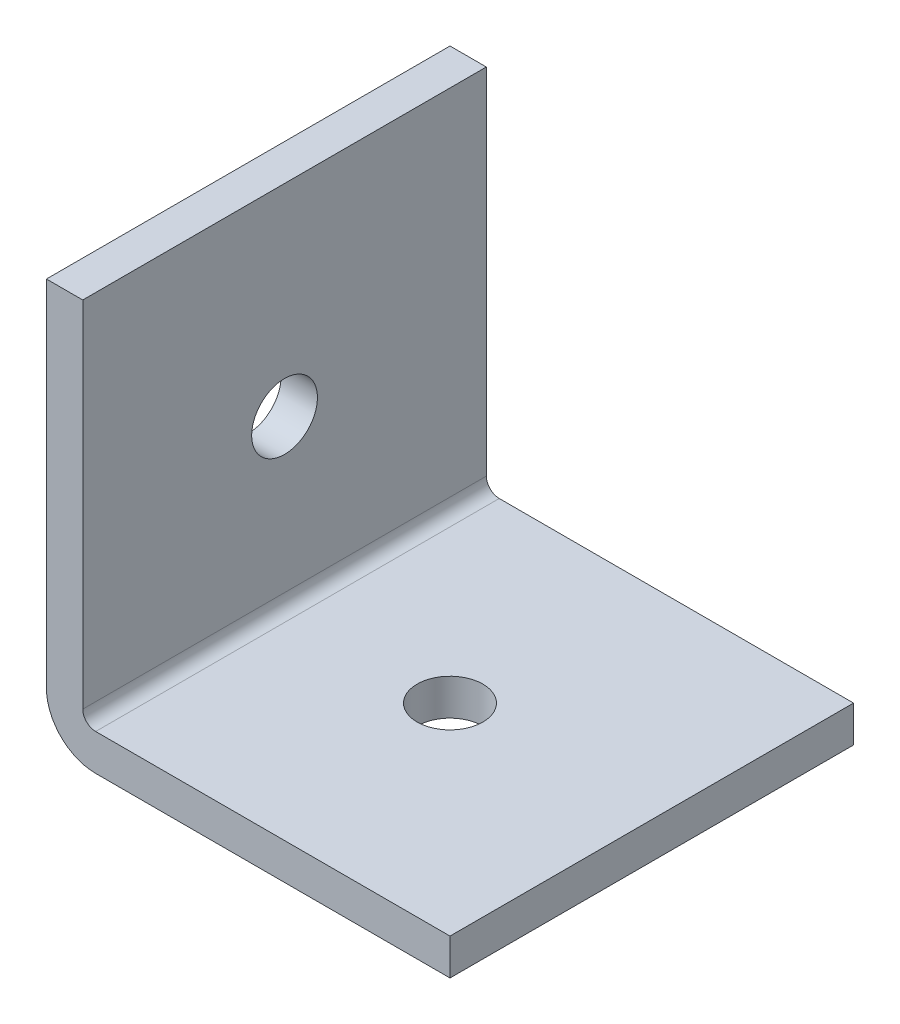
from build123d import *

# Parameters (mm, degrees)
SKETCH1_W                  = 25.4
SKETCH1_H                  = 1498.6
BOSS_EXTRUDE1_DEPTH        = 25.4
SKETCH2_W                  = 23.114
SKETCH2_H                  = 23.114
CUT_EXTRUDE1_DEPTH         = 1499.6
M3_5_CLEARANCE_HOLE1_D     = 4.1402
M3_5_CLEARANCE_HOLE1_DEPTH = 25.4
M3_5_CLEARANCE_HOLE2_D     = 4.1402
M3_5_CLEARANCE_HOLE2_DEPTH = 25.4
CHAMFER1_SIZE              = 2.159
FILLET1_R                  = 0.8128
FILLET2_R                  = 3.0988
SKETCH8_W                  = 95.882963774
SKETCH8_H                  = 79.338329604
CUT_EXTRUDE3_DEPTH         = 1371.6
SKETCH9_W                  = 56.924523055
SKETCH9_H                  = 51.282783217
CUT_EXTRUDE4_DEPTH         = 76.2
SKETCH10_W                 = 57.247248429
SKETCH10_H                 = 53.712272172
CUT_EXTRUDE5_DEPTH         = 25.4


with BuildPart() as part:
    # Sketch1 → Boss-Extrude1 (new body)
    with BuildSketch(Plane(origin=(0, 0, 0), x_dir=(0, -1, 0), z_dir=(-1, 0, 0))):
        with Locations((-12.7, 0)):
            Rectangle(SKETCH1_W, SKETCH1_H)
    extrude(amount=-BOSS_EXTRUDE1_DEPTH)

    # Sketch2 → Cut-Extrude1 (cut, through all)
    with BuildSketch(Plane(origin=(0, 0, -749.3), x_dir=(-1, 0, 0), z_dir=(0, 0, -1))):
        with Locations((-13.843, 13.843)):
            Rectangle(SKETCH2_W, SKETCH2_H)
    extrude(amount=-CUT_EXTRUDE1_DEPTH, mode=Mode.SUBTRACT)

    # M3.5 Clearance Hole1
    with Locations(Plane(origin=(0, 0, 0), x_dir=(-1, 0, 0), z_dir=(0, -1, 0))):
        with Locations((-12.7, 736.6), (-12.7, 711.2), (-12.7, 685.8), (-12.7, 660.4), (-12.7, 635), (-12.7, 609.6), (-12.7, 584.2), (-12.7, 558.8), (-12.7, 533.4), (-12.7, 508), (-12.7, 482.6), (-12.7, 457.2), (-12.7, 431.8), (-12.7, 406.4), (-12.7, 381), (-12.7, 355.6), (-12.7, 330.2), (-12.7, 304.8), (-12.7, 279.4), (-12.7, 254), (-12.7, 228.6), (-12.7, 203.2), (-12.7, 177.8), (-12.7, 152.4), (-12.7, 127), (-12.7, 101.6), (-12.7, 76.2), (-12.7, 50.8), (-12.7, 25.4), (-12.7, 0), (-12.7, -25.4), (-12.7, -50.8), (-12.7, -76.2), (-12.7, -101.6), (-12.7, -127), (-12.7, -152.4), (-12.7, -177.8), (-12.7, -203.2), (-12.7, -228.6), (-12.7, -254), (-12.7, -279.4), (-12.7, -304.8), (-12.7, -330.2), (-12.7, -355.6), (-12.7, -381), (-12.7, -406.4), (-12.7, -431.8), (-12.7, -457.2), (-12.7, -482.6), (-12.7, -508), (-12.7, -533.4), (-12.7, -558.8), (-12.7, -584.2), (-12.7, -609.6), (-12.7, -635), (-12.7, -660.4), (-12.7, -685.8), (-12.7, -711.2), (-12.7, -736.6)):
            Hole(M3_5_CLEARANCE_HOLE1_D / 2, depth=M3_5_CLEARANCE_HOLE1_DEPTH)

    # M3.5 Clearance Hole2
    with Locations(Plane.ZY):
        with Locations((711.2, 12.7), (736.6, 12.7), (685.8, 12.7), (660.4, 12.7), (635, 12.7), (609.6, 12.7), (584.2, 12.7), (558.8, 12.7), (533.4, 12.7), (508, 12.7), (482.6, 12.7), (457.2, 12.7), (431.8, 12.7), (406.4, 12.7), (381, 12.7), (355.6, 12.7), (330.2, 12.7), (304.8, 12.7), (279.4, 12.7), (254, 12.7), (228.6, 12.7), (203.2, 12.7), (177.8, 12.7), (152.4, 12.7), (127, 12.7), (101.6, 12.7), (76.2, 12.7), (50.8, 12.7), (25.4, 12.7), (0, 12.7), (-25.4, 12.7), (-50.8, 12.7), (-76.2, 12.7), (-101.6, 12.7), (-127, 12.7), (-152.4, 12.7), (-177.8, 12.7), (-203.2, 12.7), (-228.6, 12.7), (-254, 12.7), (-279.4, 12.7), (-304.8, 12.7), (-330.2, 12.7), (-355.6, 12.7), (-381, 12.7), (-406.4, 12.7), (-431.8, 12.7), (-457.2, 12.7), (-482.6, 12.7), (-508, 12.7), (-533.4, 12.7), (-558.8, 12.7), (-584.2, 12.7), (-609.6, 12.7), (-635, 12.7), (-660.4, 12.7), (-685.8, 12.7), (-711.2, 12.7), (-736.6, 12.7)):
            Hole(M3_5_CLEARANCE_HOLE2_D / 2, depth=M3_5_CLEARANCE_HOLE2_DEPTH)

    # Chamfer1
    chamfer1_edges = [part.edges().sort_by_distance(p)[0] for p in [
        (25.4, 1.143, -749.3),
        (1.143, 25.4, 749.3),
        (1.143, 25.4, -749.3),
        (25.4, 1.143, 749.3),
    ]]
    chamfer(chamfer1_edges, length=CHAMFER1_SIZE)

    # Fillet1
    fillet1_edges = [part.edges().sort_by_distance(p)[0] for p in [
        (2.286, 2.286, 0),
    ]]
    fillet(fillet1_edges, radius=FILLET1_R)

    # Fillet2
    fillet2_edges = [part.edges().sort_by_distance(p)[0] for p in [
        (0, 0, 0),
    ]]
    fillet(fillet2_edges, radius=FILLET2_R)

    # Sketch8 → Cut-Extrude3 (cut)
    with BuildSketch(Plane.XY.offset(749.3)):
        with Locations((2.286, 3.0988)):
            Rectangle(SKETCH8_W, SKETCH8_H)
    extrude(amount=-CUT_EXTRUDE3_DEPTH, mode=Mode.SUBTRACT)

    # Sketch9 → Cut-Extrude4 (cut)
    with BuildSketch(Plane(origin=(0, 0, -749.3), x_dir=(-1, 0, 0), z_dir=(0, 0, -1))):
        with Locations((-2.180776643, 1.30746368)):
            Rectangle(SKETCH9_W, SKETCH9_H)
    extrude(amount=-CUT_EXTRUDE4_DEPTH, mode=Mode.SUBTRACT)

    # Sketch10 → Cut-Extrude5 (cut)
    with BuildSketch(Plane.XY.offset(-622.3)):
        with Locations((2.141729058, 1.213934322)):
            Rectangle(SKETCH10_W, SKETCH10_H)
    extrude(amount=-CUT_EXTRUDE5_DEPTH, mode=Mode.SUBTRACT)


solid = part.part
